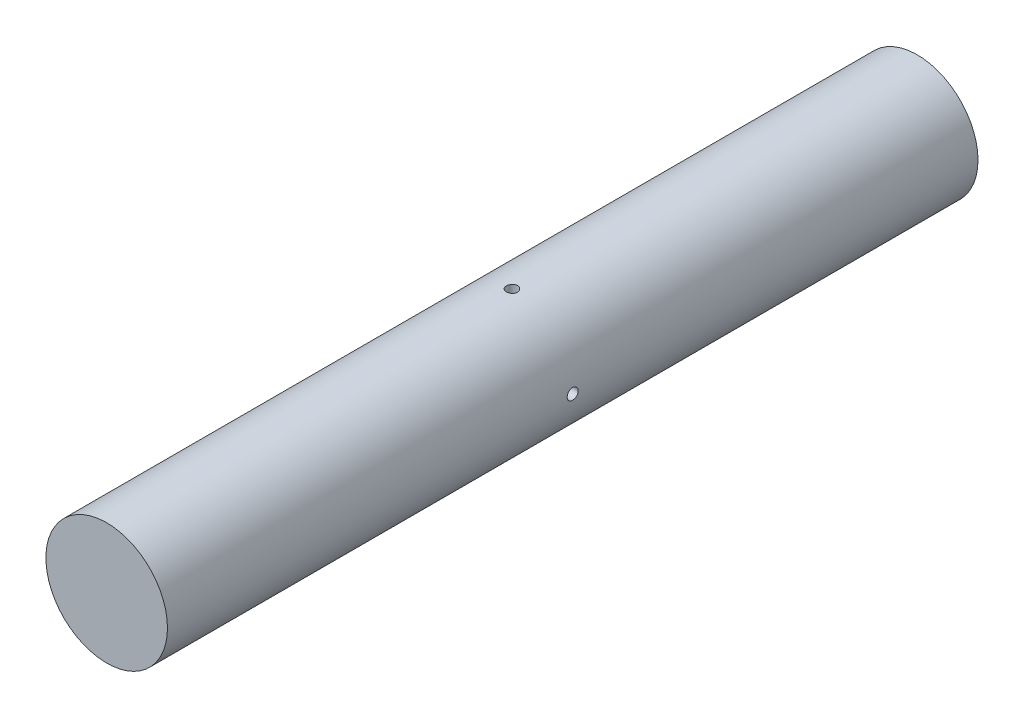
from build123d import *

# Parameters (mm, degrees)
SKETCH1_R                  = 37.5
BOSS_EXTRUDE1_DEPTH        = 250
M8X1_25_TAPPED_HOLE1_D     = 6.8
M8X1_25_TAPPED_HOLE1_DEPTH = 21.25
M8X1_25_TAPPED_HOLE1_TIP   = 2.042926105
M8X1_25_TAPPED_HOLE2_D     = 6.8
M8X1_25_TAPPED_HOLE2_DEPTH = 21.25
M8X1_25_TAPPED_HOLE2_TIP   = 2.042926105
M8X1_25_TAPPED_HOLE3_D     = 6.8
M8X1_25_TAPPED_HOLE3_DEPTH = 21.25
M8X1_25_TAPPED_HOLE3_TIP   = 2.042926105
M8X1_25_TAPPED_HOLE4_D     = 6.8
M8X1_25_TAPPED_HOLE4_DEPTH = 21.25
M8X1_25_TAPPED_HOLE4_TIP   = 2.042926105


with BuildPart() as part:
    # Sketch1 → Boss-Extrude1 (new body, symmetric)
    with BuildSketch(Plane.XY):
        Circle(SKETCH1_R)
    extrude(amount=BOSS_EXTRUDE1_DEPTH, both=True)

    # M8x1.25 Tapped Hole1
    with Locations(Plane(origin=(0, -37.5, 0), x_dir=(-1, 0, 0), z_dir=(0, -1, 0))):
        with Locations((0, 0)):
            Hole(M8X1_25_TAPPED_HOLE1_D / 2, depth=M8X1_25_TAPPED_HOLE1_DEPTH)
            with Locations((0, 0, -(M8X1_25_TAPPED_HOLE1_DEPTH + M8X1_25_TAPPED_HOLE1_TIP / 2))):  # 118° drill point
                Cone(0, M8X1_25_TAPPED_HOLE1_D / 2, M8X1_25_TAPPED_HOLE1_TIP, mode=Mode.SUBTRACT)

    # M8x1.25 Tapped Hole2
    with Locations(Plane(origin=(0, 37.5, 0), x_dir=(1, 0, 0), z_dir=(0, 1, 0))):
        with Locations((0, 0)):
            Hole(M8X1_25_TAPPED_HOLE2_D / 2, depth=M8X1_25_TAPPED_HOLE2_DEPTH)
            with Locations((0, 0, -(M8X1_25_TAPPED_HOLE2_DEPTH + M8X1_25_TAPPED_HOLE2_TIP / 2))):  # 118° drill point
                Cone(0, M8X1_25_TAPPED_HOLE2_D / 2, M8X1_25_TAPPED_HOLE2_TIP, mode=Mode.SUBTRACT)

    # M8x1.25 Tapped Hole3
    with Locations(Plane(origin=(37.5, 0, 0), x_dir=(0, 0, -1), z_dir=(1, 0, 0))):
        with Locations((0, 0)):
            Hole(M8X1_25_TAPPED_HOLE3_D / 2, depth=M8X1_25_TAPPED_HOLE3_DEPTH)
            with Locations((0, 0, -(M8X1_25_TAPPED_HOLE3_DEPTH + M8X1_25_TAPPED_HOLE3_TIP / 2))):  # 118° drill point
                Cone(0, M8X1_25_TAPPED_HOLE3_D / 2, M8X1_25_TAPPED_HOLE3_TIP, mode=Mode.SUBTRACT)

    # M8x1.25 Tapped Hole4
    with Locations(Plane.ZY.offset(37.5)):
        with Locations((0, 0)):
            Hole(M8X1_25_TAPPED_HOLE4_D / 2, depth=M8X1_25_TAPPED_HOLE4_DEPTH)
            with Locations((0, 0, -(M8X1_25_TAPPED_HOLE4_DEPTH + M8X1_25_TAPPED_HOLE4_TIP / 2))):  # 118° drill point
                Cone(0, M8X1_25_TAPPED_HOLE4_D / 2, M8X1_25_TAPPED_HOLE4_TIP, mode=Mode.SUBTRACT)


solid = part.part
